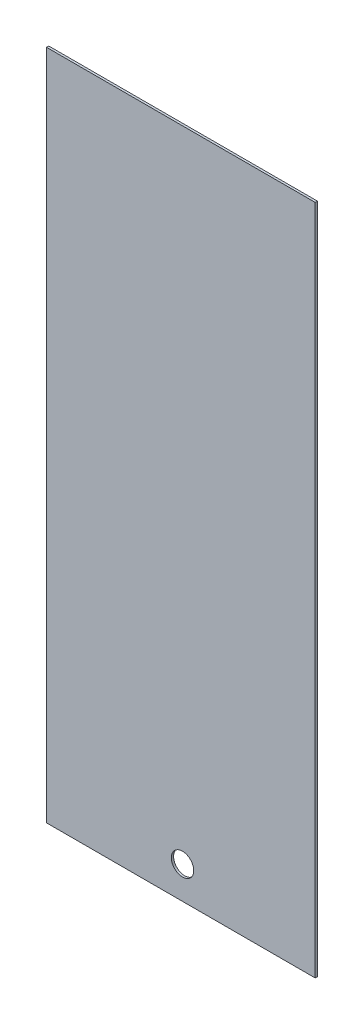
from build123d import *

# Parameters (mm, degrees)
SKETCH1_W           = 304.8
SKETCH1_H           = 762
BOSS_EXTRUDE1_DEPTH = 2.54
SKETCH2_R           = 12.7
CUT_EXTRUDE1_DEPTH  = 3.54


with BuildPart() as part:
    # Sketch1 → Boss-Extrude1 (new body)
    with BuildSketch(Plane.XY):
        with Locations((-25.068407311, -200.746214099)):
            Rectangle(SKETCH1_W, SKETCH1_H)
    extrude(amount=BOSS_EXTRUDE1_DEPTH)

    # Sketch2 → Cut-Extrude1 (cut, through all)
    with BuildSketch(Plane.XY.offset(2.54)):
        with Locations((-23.193193231, -545.162860091)):
            Circle(SKETCH2_R)
    extrude(amount=-CUT_EXTRUDE1_DEPTH, mode=Mode.SUBTRACT)


solid = part.part
